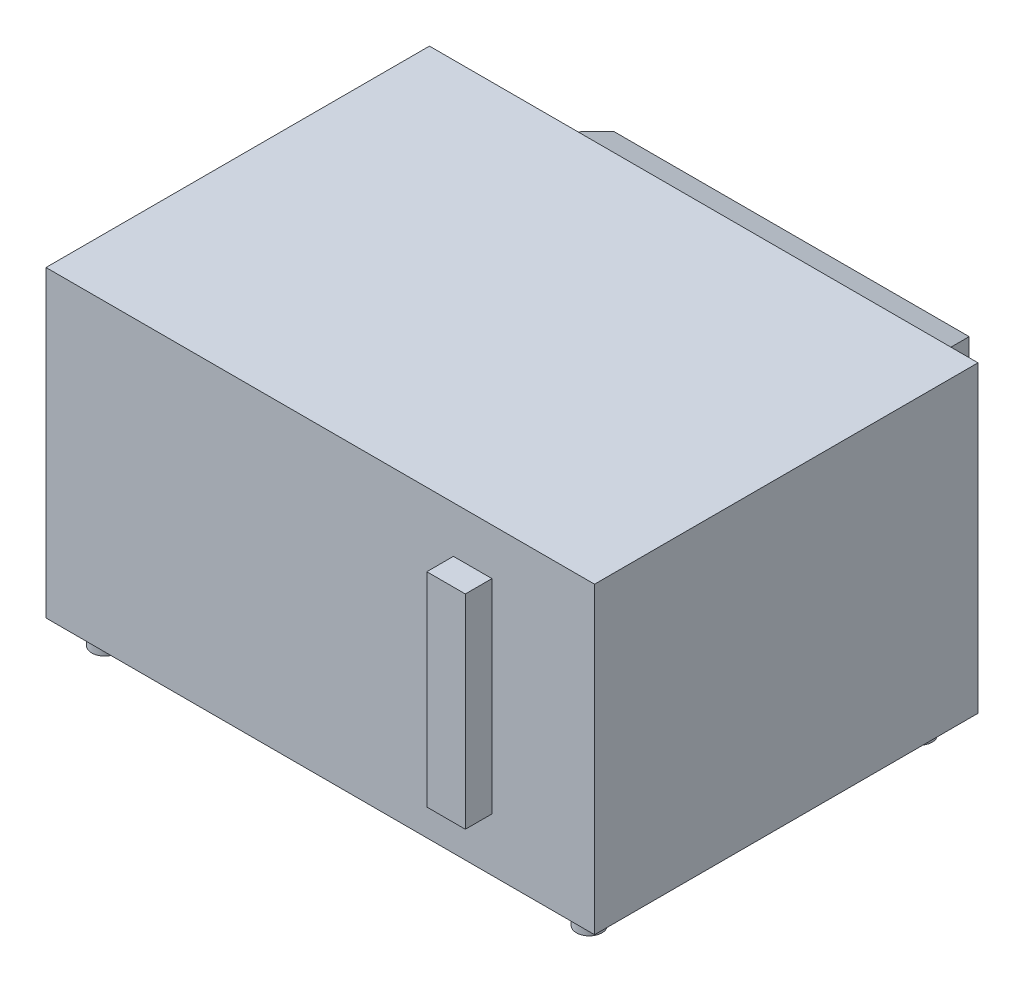
from build123d import *

# Parameters (mm, degrees)
SKETCH_2_W      = 515
SKETCH_2_H      = 360
EXTRUDE_1_DEPTH = 285
SKETCH_3_R      = 12
EXTRUDE_2_DEPTH = 20
SKETCH_4_W      = 36.17518645
SKETCH_4_H      = 191.327135514
EXTRUDE_3_DEPTH = 25
SKETCH_5_W      = 388.964610797
SKETCH_5_H      = 188.668975617
EXTRUDE_4_DEPTH = 85
EXTRUDE_4_TAPER = 18


with BuildPart() as part:
    # Эскиз2 → Бобышка-Вытянуть1 (new body)
    with BuildSketch(Plane(origin=(0, 0, 0), x_dir=(1, 0, 0), z_dir=(0, 1, 0))):
        with Locations((257.5, 180)):
            Rectangle(SKETCH_2_W, SKETCH_2_H)
    extrude(amount=EXTRUDE_1_DEPTH)

    # Эскиз3 → Бобышка-Вытянуть2 (add)
    with BuildSketch(Plane.XZ):
        with Locations((30, -25)):
            Circle(SKETCH_3_R)
        with Locations((30, -335)):
            Circle(SKETCH_3_R)
        with Locations((485, -335)):
            Circle(SKETCH_3_R)
        with Locations((485, -25)):
            Circle(SKETCH_3_R)
    extrude(amount=EXTRUDE_2_DEPTH)

    # Эскиз4 → Бобышка-Вытянуть3 (add)
    with BuildSketch(Plane.XY):
        with Locations((400.600187064, 145.73424428)):
            Rectangle(SKETCH_4_W, SKETCH_4_H)
    extrude(amount=EXTRUDE_3_DEPTH)

    # Эскиз5 → Бобышка-Вытянуть4 (add)
    with BuildSketch(Plane(origin=(0, 0, -360), x_dir=(-1, 0, 0), z_dir=(0, 0, -1))):
        with Locations((-254.857577373, 150.431495615)):
            Rectangle(SKETCH_5_W, SKETCH_5_H)
    extrude(amount=EXTRUDE_4_DEPTH, taper=EXTRUDE_4_TAPER)


solid = part.part
